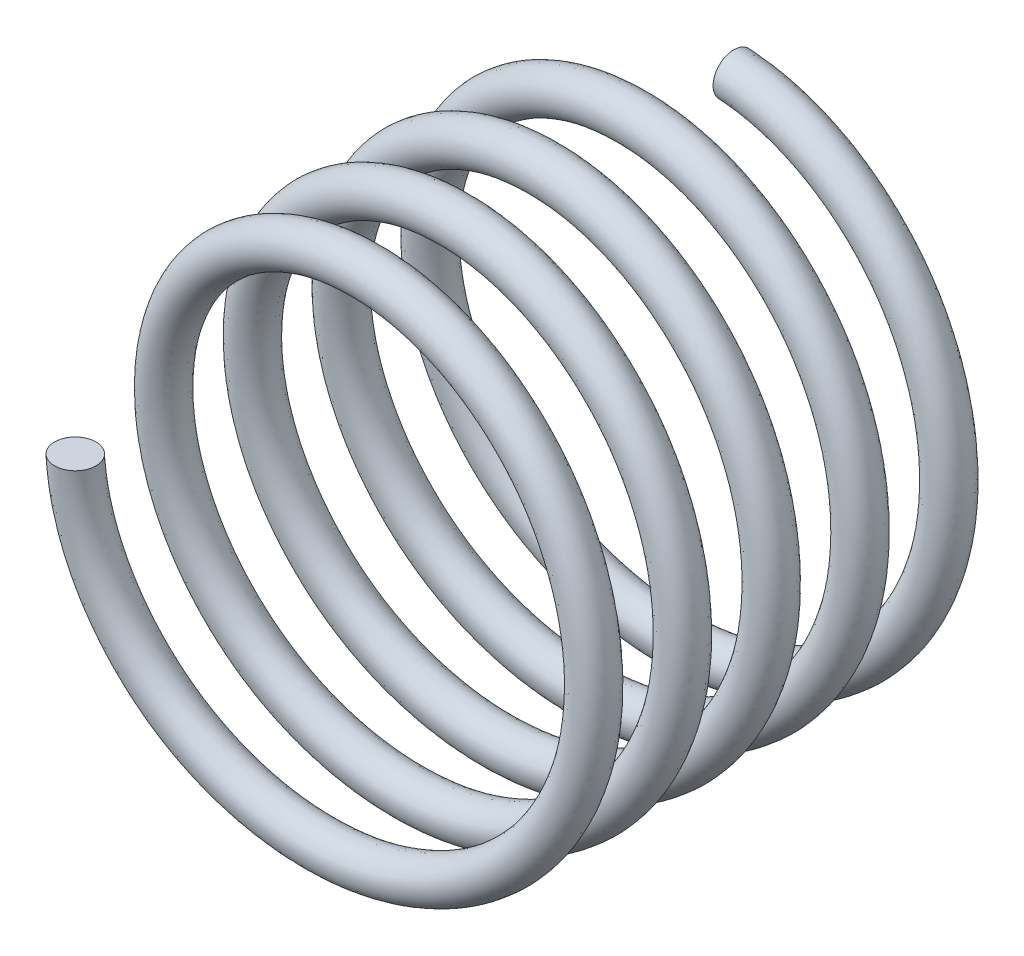
from build123d import *

# Parameters (mm, degrees)
SWEEP1_PITCH       = 0.75
SWEEP1_HEIGHT      = 3.5625
SWEEP1_RADIUS      = 2
SWEEP1_START_ANGLE = 90
SKETCH3_R          = 0.175


with BuildPart() as part:
    # Sweep1: sweep along a helix
    with BuildLine() as sweep1_path:
        add(Helix(SWEEP1_PITCH, SWEEP1_HEIGHT, SWEEP1_RADIUS, center=(0, 0, 0), direction=(0, 0, 1), lefthand=True, mode=Mode.PRIVATE).rotate(Axis((0, 0, 0), (0, 0, 1)), SWEEP1_START_ANGLE))
    # Sketch3 → Sweep1 (sweep)
    with BuildSketch(Plane(origin=(0, 0, 0), x_dir=(1, 0, 0), z_dir=(0, 1, 0))):
        with Locations((-2, -3.5625)):
            Circle(SKETCH3_R)
    sweep(path=sweep1_path.line, is_frenet=True)


solid = part.part
